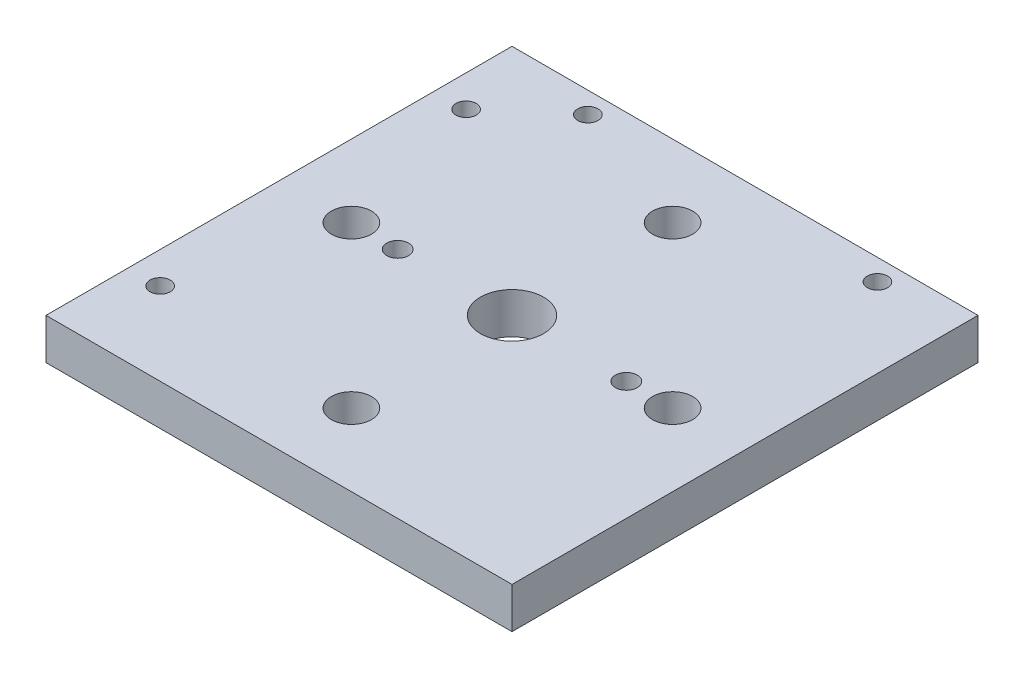
from build123d import *

# Parameters (mm, degrees)
SKETCH1_W             = 73.7
SKETCH1_H             = 73.7
SKETCH1_R             = 3.175
SKETCH1_R_2           = 5
SKETCH1_R_3           = 1.604776926
OPTICAL_MOUNT_DEPTH   = 6.477
F_8_32_TAPPED_HOLE1_D = 3.4544


with BuildPart() as part:
    # Sketch1 → optical_mount (new body)
    with BuildSketch(Plane(origin=(0, 0, 0), x_dir=(1, 0, 0), z_dir=(0, 1, 0))):
        Rectangle(SKETCH1_W, SKETCH1_H)
        with Locations((0, 25.4)):
            Circle(SKETCH1_R, mode=Mode.SUBTRACT)
        with Locations((25.4, 0)):
            Circle(SKETCH1_R, mode=Mode.SUBTRACT)
        with Locations((0, -25.4)):
            Circle(SKETCH1_R, mode=Mode.SUBTRACT)
        with Locations((-25.4, 0)):
            Circle(SKETCH1_R, mode=Mode.SUBTRACT)
        Circle(SKETCH1_R_2, mode=Mode.SUBTRACT)
        with Locations((24.309899871, 33.48518084)):
            Circle(SKETCH1_R_3, mode=Mode.SUBTRACT)
        with Locations((-21.487964718, 33.48518084)):
            Circle(SKETCH1_R_3, mode=Mode.SUBTRACT)
        with Locations((-31.85729255, 24.597185555)):
            Circle(SKETCH1_R_3, mode=Mode.SUBTRACT)
        with Locations((-31.85729255, -23.793010992)):
            Circle(SKETCH1_R_3, mode=Mode.SUBTRACT)
    extrude(amount=OPTICAL_MOUNT_DEPTH)

    # #8-32 Tapped Hole1 (through all)
    with Locations(Plane(origin=(-18.08, 6.477, 0), x_dir=(0, 0, 1), z_dir=(0, 1, 0))):
        with Locations((0, 0), (0, 36.16)):
            Hole(F_8_32_TAPPED_HOLE1_D / 2)


solid = part.part
